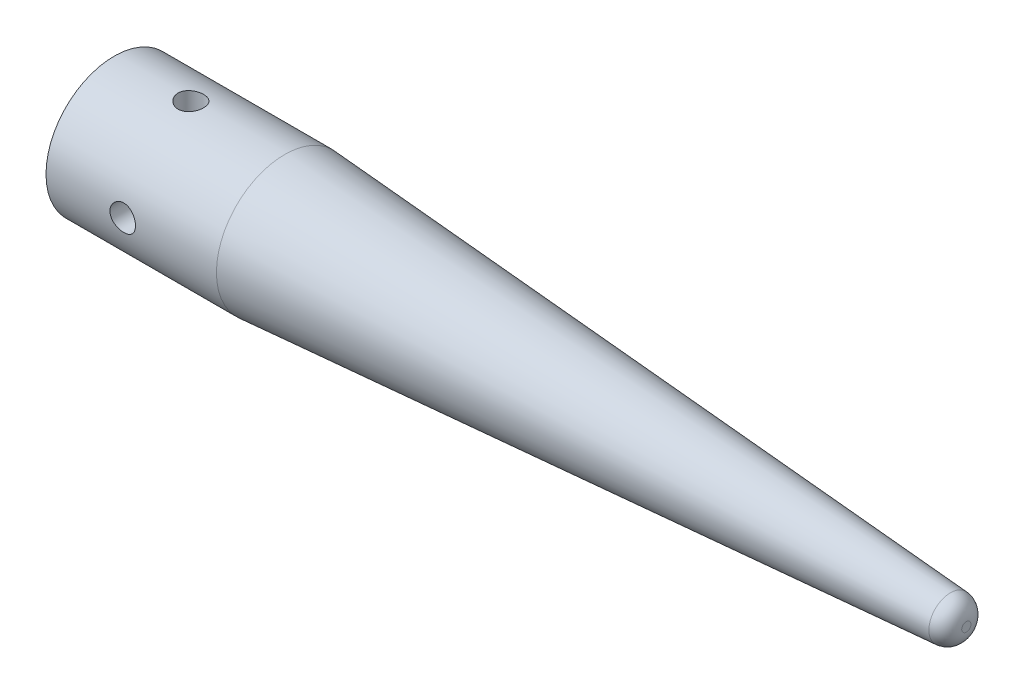
from build123d import *

# Parameters (mm, degrees)
ENL_V_MAT_EXTRU_1_DEPTH      = 15
ESQUISSE3_R                  = 1.5
ENL_V_MAT_EXTRU_2_DEPTH      = 9
ENL_V_MAT_EXTRU_2_DEPTH_BACK = 9
ESQUISSE4_R                  = 1.5
ENL_V_MAT_EXTRU_3_DEPTH      = 9.0000001
ENL_V_MAT_EXTRU_3_DEPTH_BACK = 9.0000001


with BuildPart() as part:
    # Esquisse1 → Révolution1 (revolve)
    with BuildSketch(Plane.XY, mode=Mode.PRIVATE) as r_volution1_sk:
        with BuildLine():
            Line((7.9, 0), (0, 7.9))
            Line((0, 7.9), (0, 8))
            Line((0, 8), (20, 8))
            Line((20, 8), (98.139512947, 2.535952973))
            ThreePointArc((98.139512947, 2.535952973), (99.462707403, 1.904821592), (100, 0.540824872))
            Line((100, 0.540824872), (100, 0))
            Line((100, 0), (7.9, 0))
        make_face()
    revolve(r_volution1_sk.sketch.rotate(Axis((0, 0, 0), (1, 0, 0)), 90), axis=Axis((0, 0, 0), (1, 0, 0)))  # turned: the seam where the file's is

    # Esquisse2 → Enlèv. mat.-Extru.1 (cut)
    with BuildSketch(Plane(origin=(0, 0, 0), x_dir=(0, 0, -1), z_dir=(1, 0, 0))):
        with BuildLine():
            Line((4, 5), (-4, 5))
            ThreePointArc((-4, 5), (-4.707106781, 4.707106781), (-5, 4))
            Line((-5, 4), (-5, -4))
            ThreePointArc((-5, -4), (-4.707106781, -4.707106781), (-4, -5))
            Line((-4, -5), (4, -5))
            ThreePointArc((4, -5), (4.707106781, -4.707106781), (5, -4))
            Line((5, -4), (5, 4))
            ThreePointArc((5, 4), (4.707106781, 4.707106781), (4, 5))
        make_face()
    extrude(amount=ENL_V_MAT_EXTRU_1_DEPTH, mode=Mode.SUBTRACT)

    # Esquisse3 → Enlèv. mat.-Extru.2 (cut, two sides)
    with BuildSketch(Plane(origin=(0, 0, 0), x_dir=(1, 0, 0), z_dir=(0, 1, 0))) as enl_v_mat_extru_2_sk:
        with Locations(Location((9, 0, 0), (0, 0, 270))):  # turned: the seam where the file's is
            Circle(ESQUISSE3_R)
    extrude(amount=ENL_V_MAT_EXTRU_2_DEPTH, mode=Mode.SUBTRACT)
    extrude(enl_v_mat_extru_2_sk.sketch, amount=-ENL_V_MAT_EXTRU_2_DEPTH_BACK, mode=Mode.SUBTRACT)

    # Esquisse4 → Enlèv. mat.-Extru.3 (cut, two sides)
    with BuildSketch(Plane.XY) as enl_v_mat_extru_3_sk:
        with Locations((9, 0)):
            Circle(ESQUISSE4_R)
    extrude(amount=ENL_V_MAT_EXTRU_3_DEPTH, mode=Mode.SUBTRACT)
    extrude(enl_v_mat_extru_3_sk.sketch, amount=-ENL_V_MAT_EXTRU_3_DEPTH_BACK, mode=Mode.SUBTRACT)


solid = part.part
